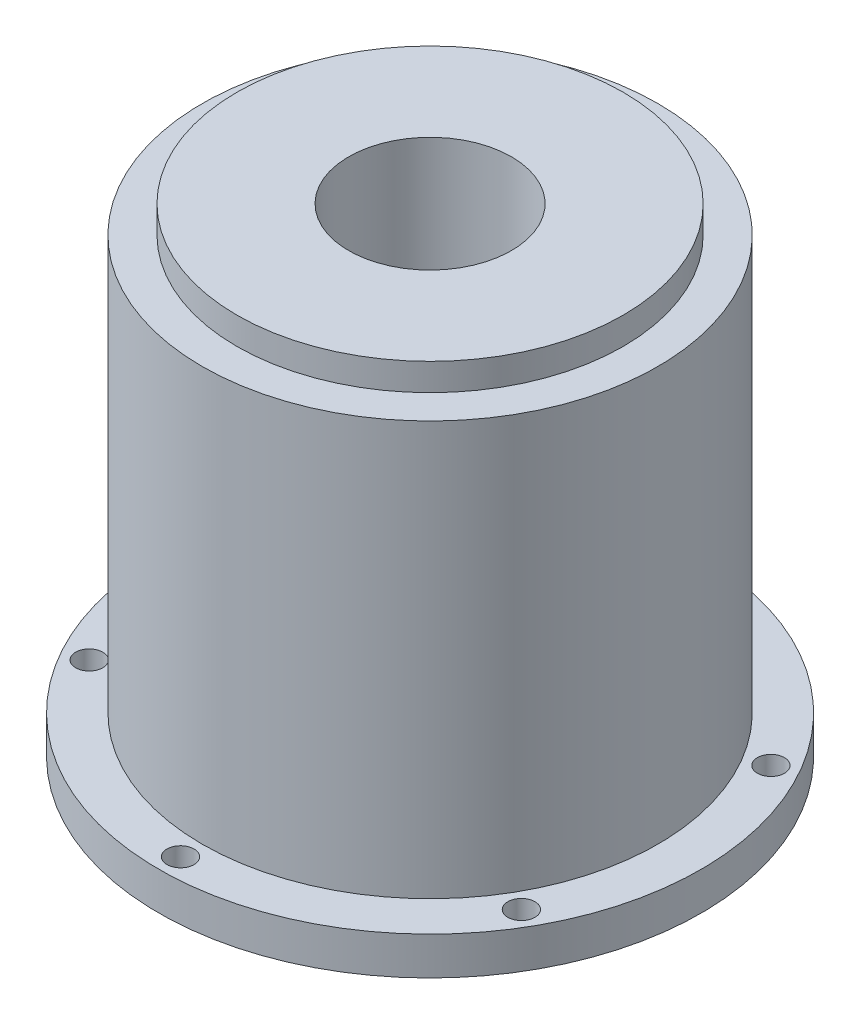
from build123d import *

# Parameters (mm, degrees)
SKETCH2_R          = 1.25
CUT_EXTRUDE1_DEPTH = 10
SKETCH4_R          = 1.25
CUT_EXTRUDE2_DEPTH = 10


with BuildPart() as part:
    # Sketch1 → Revolve1 (revolve)
    with BuildSketch(Plane.XY):
        Polygon((7.5, 57.821876273), (7.5, 7.221876273), (15, 7.221876273), (15, 13.686423943), (25, 13.686423943), (25, 17.186423943), (21, 17.186423943), (21, 55.321876273), (17.801767056, 55.321876273), (17.801767056, 57.821876273), align=None)
        Polygon((8.7, 53.521876273), (19.6, 53.521876273), (19.6, 15.931935651), (13.113770226, 15.931935651), (13.113770226, 12.516887812), (8.7, 12.516887812), align=None, mode=Mode.SUBTRACT)
    revolve(axis=Axis((0, 0, 0), (0, 1, 0)))

    # Sketch2 → Cut-Extrude1 (cut)
    with BuildSketch(Plane(origin=(0, 17.186423943, 0), x_dir=(1, 0, 0), z_dir=(0, 1, 0))):
        with Locations((0, 23)):
            Circle(SKETCH2_R)
        with Locations((19.918584287, 11.5)):
            Circle(SKETCH2_R)
        with Locations((19.918584287, -11.5)):
            Circle(SKETCH2_R)
        with Locations((0, -23)):
            Circle(SKETCH2_R)
        with Locations((-19.918584287, -11.5)):
            Circle(SKETCH2_R)
        with Locations((-19.918584287, 11.5)):
            Circle(SKETCH2_R)
    extrude(amount=-CUT_EXTRUDE1_DEPTH, mode=Mode.SUBTRACT)

    # Sketch4 → Cut-Extrude2 (cut)
    with BuildSketch(Plane(origin=(0, 12.516887812, 0), x_dir=(1, 0, 0), z_dir=(0, 1, 0))):
        with Locations((0, 11)):
            Circle(SKETCH4_R)
        with Locations((9.526279442, 5.5)):
            Circle(SKETCH4_R)
        with Locations((9.526279442, -5.5)):
            Circle(SKETCH4_R)
        with Locations((0, -11)):
            Circle(SKETCH4_R)
        with Locations((-9.526279442, -5.5)):
            Circle(SKETCH4_R)
        with Locations((-9.526279442, 5.5)):
            Circle(SKETCH4_R)
    extrude(amount=-CUT_EXTRUDE2_DEPTH, mode=Mode.SUBTRACT)


solid = part.part
